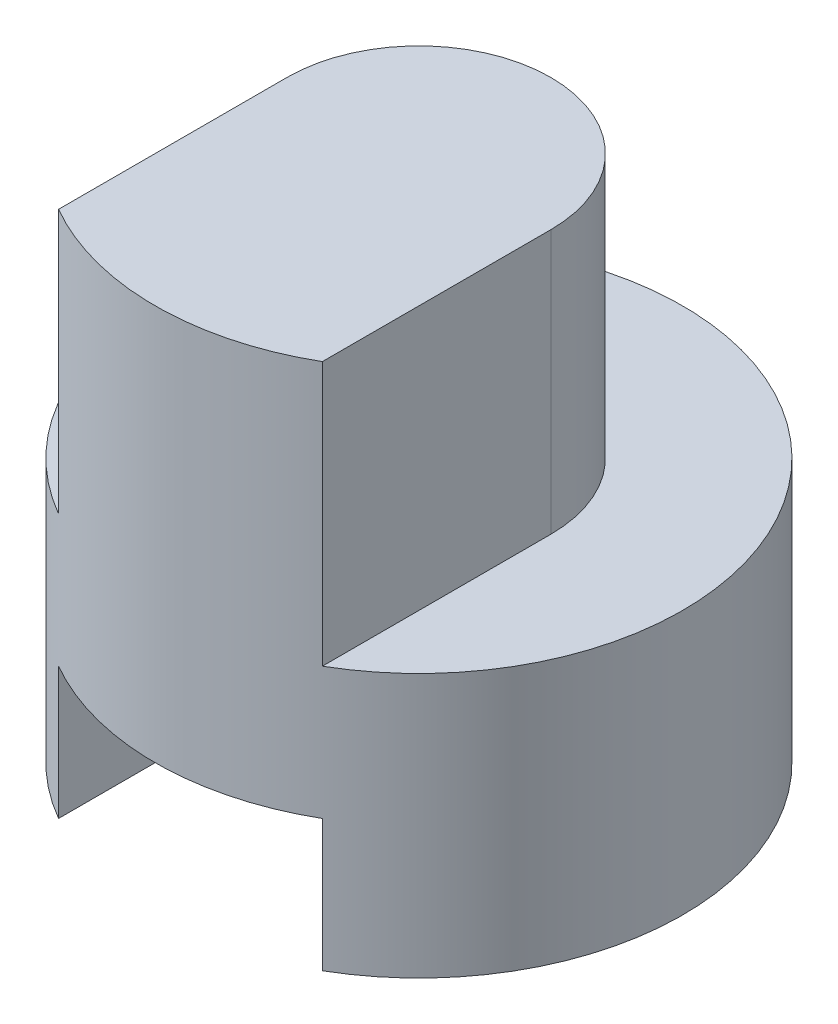
from build123d import *

# Parameters (mm, degrees)
SKETCH1_R           = 2
BOSS_EXTRUDE1_DEPTH = 2
BOSS_EXTRUDE2_DEPTH = 2
CUT_EXTRUDE1_DEPTH  = 1


with BuildPart() as part:
    # Sketch1 → Boss-Extrude1 (new body)
    with BuildSketch(Plane(origin=(0, 0, 0), x_dir=(1, 0, 0), z_dir=(0, 1, 0))):
        Circle(SKETCH1_R)
    extrude(amount=BOSS_EXTRUDE1_DEPTH)

    # Sketch2 → Boss-Extrude2 (add)
    with BuildSketch(Plane(origin=(0, 2, 0), x_dir=(1, 0, 0), z_dir=(0, 1, 0))):
        with BuildLine():
            Line((-1, -1.732050808), (-1, 0))
            ThreePointArc((-1, 0), (0, 1), (1, 0))
            Line((1, 0), (1, -1.732050808))
            ThreePointArc((1, -1.732050808), (0, -2), (-1, -1.732050808))
        make_face()
    extrude(amount=BOSS_EXTRUDE2_DEPTH)

    # Sketch3 → Cut-Extrude1 (cut)
    with BuildSketch(Plane.XZ):
        with BuildLine():
            Line((-1, 1.732050808), (-1, 0))
            ThreePointArc((-1, 0), (0, -1), (1, 0))
            Line((1, 0), (1, 1.732050808))
            ThreePointArc((1, 1.732050808), (0, 2), (-1, 1.732050808))
        make_face()
    extrude(amount=-CUT_EXTRUDE1_DEPTH, mode=Mode.SUBTRACT)


solid = part.part
